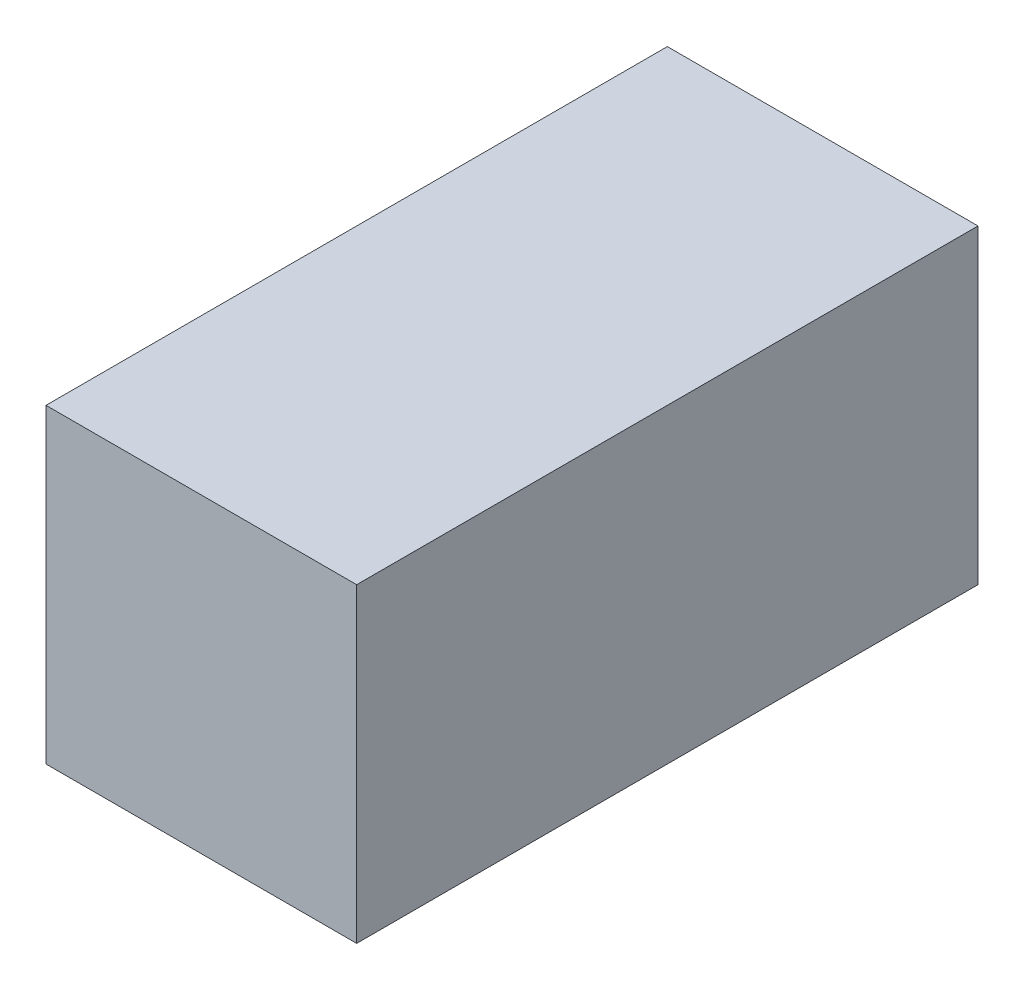
from build123d import *

# Parameters (mm, degrees)
COMPRESSOR_CROSS_SECTION_W = 127
COMPRESSOR_CROSS_SECTION_H = 127
AIR_COMPRESSOR_DEPTH       = 127


with BuildPart() as part:
    # Compressor Cross Section → Air Compressor (new body, symmetric)
    with BuildSketch(Plane.XY):
        Rectangle(COMPRESSOR_CROSS_SECTION_W, COMPRESSOR_CROSS_SECTION_H)
    extrude(amount=AIR_COMPRESSOR_DEPTH, both=True)


solid = part.part
